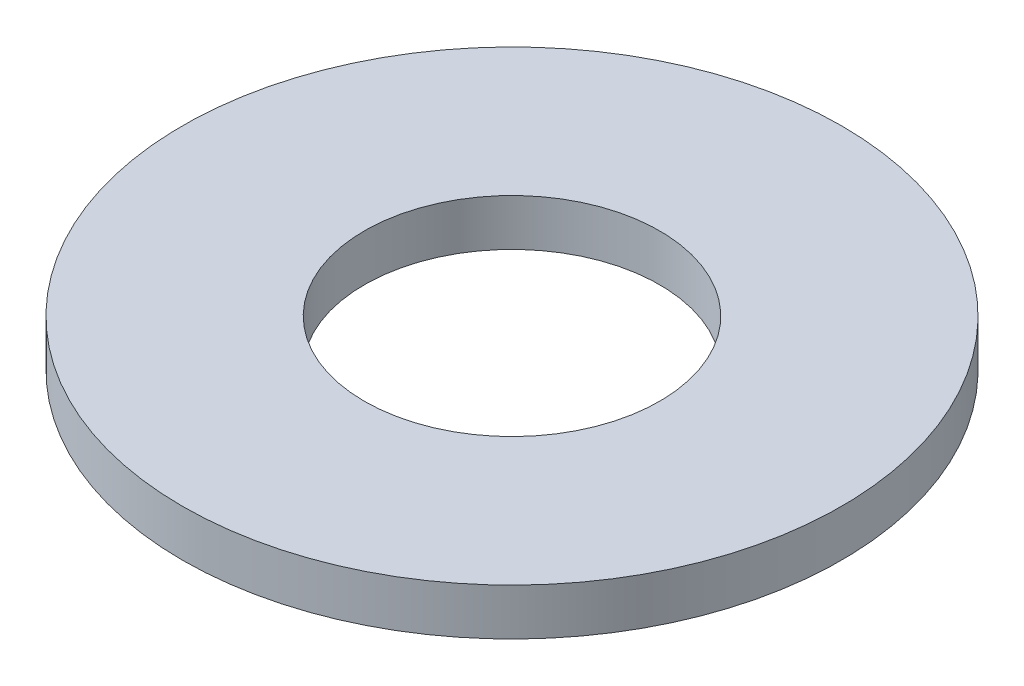
from build123d import *

# Parameters (mm, degrees)
SKETCH1_R           = 11.1125
SKETCH1_R_2         = 4.9784
BOSS_EXTRUDE1_DEPTH = 1.5748


with BuildPart() as part:
    # Sketch1 → Boss-Extrude1 (new body)
    with BuildSketch(Plane(origin=(0, 0, 0), x_dir=(1, 0, 0), z_dir=(0, 1, 0))):
        Circle(SKETCH1_R)
        Circle(SKETCH1_R_2, mode=Mode.SUBTRACT)
    extrude(amount=BOSS_EXTRUDE1_DEPTH)


solid = part.part
